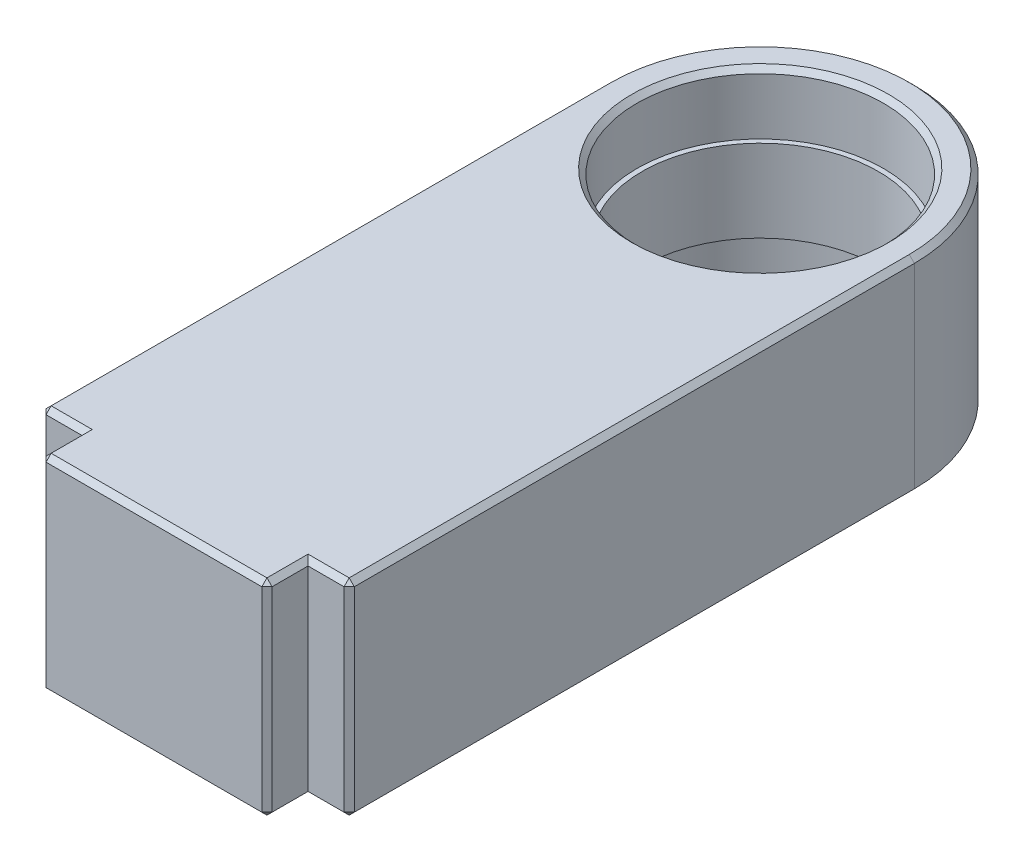
from build123d import *

# Parameters (mm, degrees)
SKETCH1_R           = 12
BOSS_EXTRUDE1_DEPTH = 10
SKETCH2_R           = 12
SKETCH2_R_2         = 11.5
BOSS_EXTRUDE2_DEPTH = 4
SKETCH3_W           = 22
SKETCH3_H           = 20
BOSS_EXTRUDE3_DEPTH = 4
CHAMFER2_SIZE       = 0.5


with BuildPart() as part:
    # Sketch1 → Boss-Extrude1 (new body, symmetric)
    with BuildSketch(Plane(origin=(0, 0, 0), x_dir=(1, 0, 0), z_dir=(0, 1, 0))):
        with BuildLine():
            Line((15, -55), (-15, -55))
            Line((-15, -55), (-15, 0))
            ThreePointArc((-15, 0), (0, 15), (15, 0))
            Line((15, 0), (15, -55))
        make_face()
        Circle(SKETCH1_R, mode=Mode.SUBTRACT)
    extrude(amount=BOSS_EXTRUDE1_DEPTH, both=True)

    # Sketch2 → Boss-Extrude2 (add, symmetric)
    with BuildSketch(Plane(origin=(0, 0, 0), x_dir=(1, 0, 0), z_dir=(0, 1, 0))):
        Circle(SKETCH2_R)
        Circle(SKETCH2_R_2, mode=Mode.SUBTRACT)
    extrude(amount=BOSS_EXTRUDE2_DEPTH, both=True)

    # Sketch3 → Boss-Extrude3 (add)
    with BuildSketch(Plane.XY.offset(55)):
        Rectangle(SKETCH3_W, SKETCH3_H)
    extrude(amount=BOSS_EXTRUDE3_DEPTH)

    # Chamfer2
    chamfer2_edges = [part.edges().sort_by_distance(p)[0] for p in [
        (-15, 10, 27.5),
        (-12, -10, 0),
        (-12, 10, 0),
        (-13, 10, 55),
        (13, -10, 55),
        (13, 10, 55),
        (-11, 10, 57),
        (-11, -10, 57),
        (11, -10, 57),
        (11, 10, 57),
        (-11, 0, 59),
        (0, -10, 59),
        (11, 0, 59),
        (0, 10, 59),
        (15, 10, 27.5),
        (-13, -10, 55),
        (-15, -10, 27.5),
        (0, -10, -15),
        (15, -10, 27.5),
        (0, 10, -15),
        (15, 0, 55),
        (-15, 0, 55),
    ]]
    chamfer(chamfer2_edges, length=CHAMFER2_SIZE)


solid = part.part
